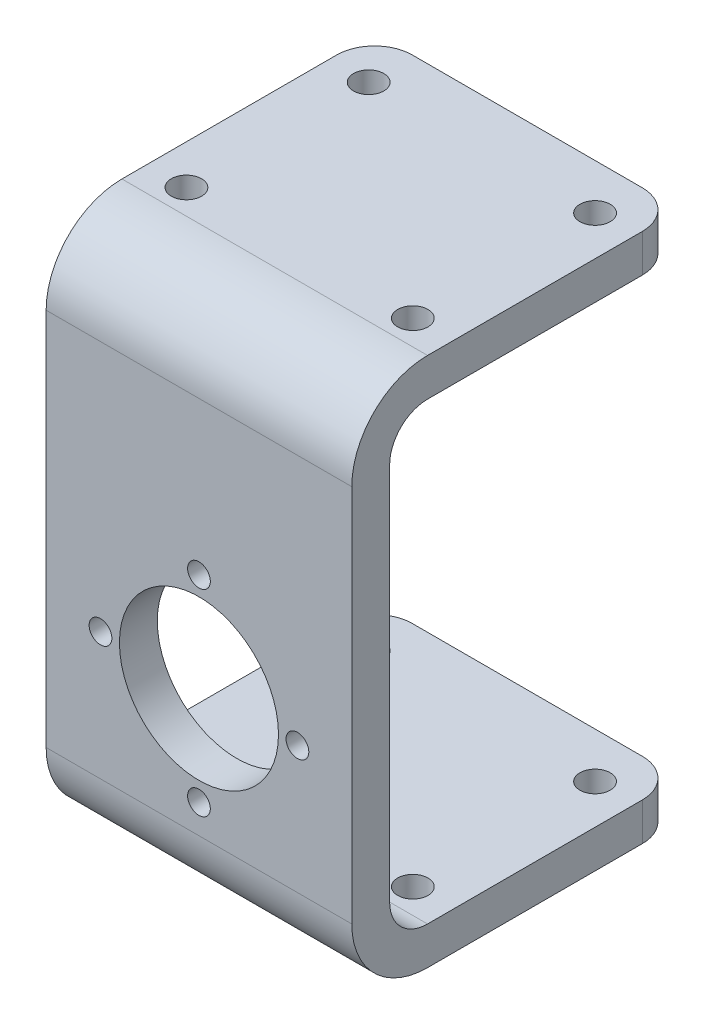
from build123d import *

# Parameters (mm, degrees)
SKETCH1_W                = 40.35
SKETCH1_H                = 43.35
BOSS_EXTRUDE1_DEPTH      = 47
CUT_EXTRUDE2_DEPTH       = 102
FILLET1_R                = 10
CUT_EXTRUDE3_DEPTH       = 102
FILLET2_R                = 5
SKETCH7_R                = 10.5
SKETCH7_R_2              = 1.5
CUT_EXTRUDE5_DEPTH       = 10
SKETCH8_W                = 40.35
SKETCH8_H                = 43.175
BOSS_EXTRUDE2_DEPTH      = 38.35
BOSS_EXTRUDE2_DEPTH_BACK = 5
SKETCH6_R                = 2
CUT_EXTRUDE4_DEPTH       = 102
CUT_EXTRUDE4_DEPTH_BACK  = 102
CUT_EXTRUDE6_DEPTH       = 50
FILLET3_R                = 5
SKETCH10_R               = 10.5
SKETCH10_R_2             = 1.5
CUT_EXTRUDE7_DEPTH       = 50


with BuildPart() as part:
    # Sketch1 → Boss-Extrude1 (new body)
    with BuildSketch(Plane(origin=(0, 0, 0), x_dir=(1, 0, 0), z_dir=(0, 1, 0))):
        with Locations((-26.966212793, -29.108023223)):
            Rectangle(SKETCH1_W, SKETCH1_H)
    extrude(amount=BOSS_EXTRUDE1_DEPTH)

    # Sketch3 → Cut-Extrude2 (cut)
    with BuildSketch(Plane.XY.offset(50.783023223)):
        with BuildLine():
            Line((-47.141212793, 47), (-47.141212793, 26.825))
            ThreePointArc((-47.141212793, 26.825), (-41.232092103, 41.09087931), (-26.966212793, 47))
            Line((-26.966212793, 47), (-47.141212793, 47))
        make_face()
        with BuildLine():
            Line((-6.791212793, 47), (-26.966212793, 47))
            ThreePointArc((-26.966212793, 47), (-12.700333482, 41.09087931), (-6.791212793, 26.825))
            Line((-6.791212793, 26.825), (-6.791212793, 47))
        make_face()
    extrude(amount=-CUT_EXTRUDE2_DEPTH, mode=Mode.SUBTRACT)

    # Fillet1
    fillet1_edges = [part.edges().sort_by_distance(p)[0] for p in [
        (-26.966212793, 0, 50.783023223),
    ]]
    fillet(fillet1_edges, radius=FILLET1_R)

    # Sketch5 → Cut-Extrude3 (cut)
    with BuildSketch(Plane.ZY.offset(47.141212793)):
        with BuildLine():
            Line((-6.665763497, 5), (36.595559978, 5))
            Line((36.595559978, 5), (40.783023223, 5))
            ThreePointArc((40.783023223, 5), (44.318557129, 6.464466094), (45.783023223, 10))
            Line((45.783023223, 10), (45.783023223, 17.578484004))
            Line((45.783023223, 17.578484004), (45.783023223, 59.778436909))
            Line((45.783023223, 59.778436909), (-6.665763497, 59.778436909))
            Line((-6.665763497, 59.778436909), (-6.665763497, 5))
        make_face()
    extrude(amount=-CUT_EXTRUDE3_DEPTH, mode=Mode.SUBTRACT)

    # Fillet2
    fillet2_edges = [part.edges().sort_by_distance(p)[0] for p in [
        (-6.791212793, 2.5, 7.433023223),
        (-47.141212793, 2.5, 7.433023223),
    ]]
    fillet(fillet2_edges, radius=FILLET2_R)

    # Sketch7 → Cut-Extrude5 (cut)
    with BuildSketch(Plane.XY.offset(50.783023223)):
        with Locations((-26.966212793, 26.825)):
            Circle(SKETCH7_R)
        with Locations((-26.966212793, 39.825)):
            Circle(SKETCH7_R_2)
        with Locations((-13.966212793, 26.825)):
            Circle(SKETCH7_R_2)
        with Locations((-26.966212793, 13.825)):
            Circle(SKETCH7_R_2)
        with Locations((-39.966212793, 26.825)):
            Circle(SKETCH7_R_2)
    extrude(amount=-CUT_EXTRUDE5_DEPTH, mode=Mode.SUBTRACT)

    # Sketch8 → Boss-Extrude2 (add, two sides)
    with BuildSketch(Plane(origin=(0, 0, 45.783023223), x_dir=(-1, 0, 0), z_dir=(0, 0, -1))) as boss_extrude2_sk:
        with Locations((26.966212793, 48.4125)):
            Rectangle(SKETCH8_W, SKETCH8_H)
    extrude(amount=BOSS_EXTRUDE2_DEPTH)
    extrude(boss_extrude2_sk.sketch, amount=-BOSS_EXTRUDE2_DEPTH_BACK)

    # Sketch6 → Cut-Extrude4 (cut, two sides)
    with BuildSketch(Plane(origin=(0, 5, 0), x_dir=(1, 0, 0), z_dir=(0, 1, 0))) as cut_extrude4_sk:
        with Locations((-41.911212793, -13.433023223)):
            Circle(SKETCH6_R)
        with Locations((-12.021212793, -13.433023223)):
            Circle(SKETCH6_R)
        with Locations((-41.911212793, -37.493023223)):
            Circle(SKETCH6_R)
        with Locations((-12.021212793, -37.493023223)):
            Circle(SKETCH6_R)
    extrude(amount=CUT_EXTRUDE4_DEPTH, mode=Mode.SUBTRACT)
    extrude(cut_extrude4_sk.sketch, amount=-CUT_EXTRUDE4_DEPTH_BACK, mode=Mode.SUBTRACT)

    # Sketch9 → Cut-Extrude6 (cut)
    with BuildSketch(Plane(origin=(-6.791212793, 0, 0), x_dir=(0, 0, -1), z_dir=(1, 0, 0))):
        with BuildLine():
            Line((-7.433023223, 26.825), (-7.433023223, 65.000002288))
            Line((-7.433023223, 65.000002288), (-40.777808898, 65.000002288))
            ThreePointArc((-40.777808898, 65.000002288), (-44.31533911, 63.535699871), (-45.783023223, 59.99957135))
            Line((-45.783023223, 59.99957135), (-45.783023223, 26.825))
            Line((-45.783023223, 26.825), (-7.433023223, 26.825))
        make_face()
        with BuildLine():
            ThreePointArc((-50.783023223, 59.997178226), (-47.853264556, 67.070241334), (-40.780201449, 70))
            Line((-40.780201449, 70), (-50.783023223, 70))
            Line((-50.783023223, 70), (-50.783023223, 59.997178226))
        make_face()
    extrude(amount=-CUT_EXTRUDE6_DEPTH, mode=Mode.SUBTRACT)

    # Fillet3
    fillet3_edges = [part.edges().sort_by_distance(p)[0] for p in [
        (-47.141212793, 67.500001144, 7.433023223),
        (-6.791212793, 67.500001144, 7.433023223),
    ]]
    fillet(fillet3_edges, radius=FILLET3_R)

    # Sketch10 → Cut-Extrude7 (cut)
    with BuildSketch(Plane.XY.offset(50.783023223)):
        with Locations((-26.966212793, 26.825)):
            Circle(SKETCH10_R)
        with Locations((-13.966212793, 26.825)):
            Circle(SKETCH10_R_2)
        with Locations((-26.966212793, 13.825)):
            Circle(SKETCH10_R_2)
        with Locations((-39.966212793, 26.825)):
            Circle(SKETCH10_R_2)
        with Locations((-26.966212793, 39.825)):
            Circle(SKETCH10_R_2)
    extrude(amount=-CUT_EXTRUDE7_DEPTH, mode=Mode.SUBTRACT)


solid = part.part
